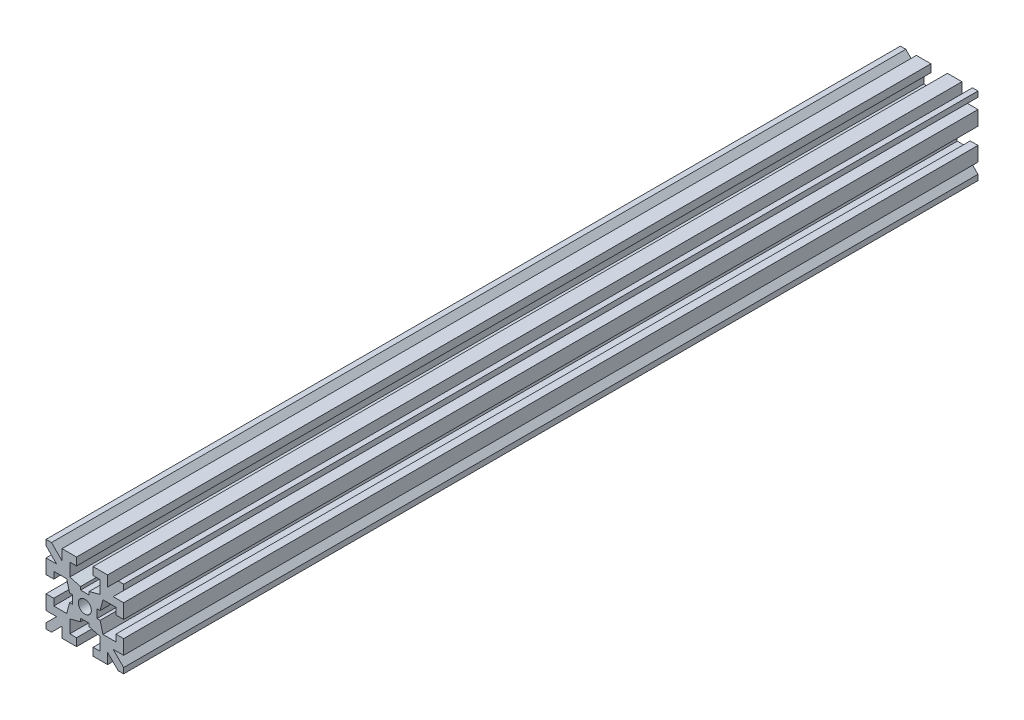
from build123d import *

# Parameters (mm, degrees)
RESSALTO_EXTRUS_O1_DEPTH   = 82.5
ESPELHAR2_COPY_1_DEPTH     = 82.5
ESBO_O2_R                  = 1.25
CORTE_EXTRUS_O1_DEPTH      = 1
CORTE_EXTRUS_O1_DEPTH_BACK = 166


with BuildPart() as part:
    # Esboço1 → Ressalto-extrusão1 (new body, symmetric)
    with BuildSketch(Plane.XY):
        Polygon((0, 2.35), (-0.825, 2.35), (-0.825, 2.95), (-2.9, 3.5), (-2.9, 6), (-1.6, 6), (-1.6, 7.5), (-4.4, 7.5), (-4.4, 5.460660172), (-6.439339828, 7.5), (-7.5, 7.5), (-7.5, 6.439339828), (-5.460660172, 4.4), (-7.5, 4.4), (-7.5, 1.6), (-6, 1.6), (-6, 2.9), (-3.5, 2.9), (-2.95, 0.825), (-2.35, 0.825), (-2.35, 0), (0, 0), align=None)
    ressalto_extrus_o1 = extrude(amount=RESSALTO_EXTRUS_O1_DEPTH, both=True)

    # Espelhar1: Ressalto-extrusão1 across plane
    add(ressalto_extrus_o1.mirror(Plane.ZX))

    # Espelhar2: Ressalto-extrusão1 across plane
    add(ressalto_extrus_o1.mirror(Plane(origin=(0, 0, 0), x_dir=(0, 0, 1), z_dir=(1, 0, 0))))

    # Espelhar2 copy 1 sketch → Espelhar2 copy 1 (add, symmetric)
    with BuildSketch(Plane(origin=(0, 0, 0), x_dir=(-1, 0, 0), z_dir=(0, 0, 1))):
        Polygon((0, 2.35), (-0.825, 2.35), (-0.825, 2.95), (-2.9, 3.5), (-2.9, 6), (-1.6, 6), (-1.6, 7.5), (-4.4, 7.5), (-4.4, 5.460660172), (-6.439339828, 7.5), (-7.5, 7.5), (-7.5, 6.439339828), (-5.460660172, 4.4), (-7.5, 4.4), (-7.5, 1.6), (-6, 1.6), (-6, 2.9), (-3.5, 2.9), (-2.95, 0.825), (-2.35, 0.825), (-2.35, 0), (0, 0), align=None)
    extrude(amount=ESPELHAR2_COPY_1_DEPTH, both=True)

    # Esboço2 → Corte-extrusão1 (cut, two sides)
    with BuildSketch(Plane.XY.offset(82.5)) as corte_extrus_o1_sk:
        Circle(ESBO_O2_R)
    extrude(amount=CORTE_EXTRUS_O1_DEPTH, mode=Mode.SUBTRACT)
    extrude(corte_extrus_o1_sk.sketch, amount=-CORTE_EXTRUS_O1_DEPTH_BACK, mode=Mode.SUBTRACT)


solid = part.part
